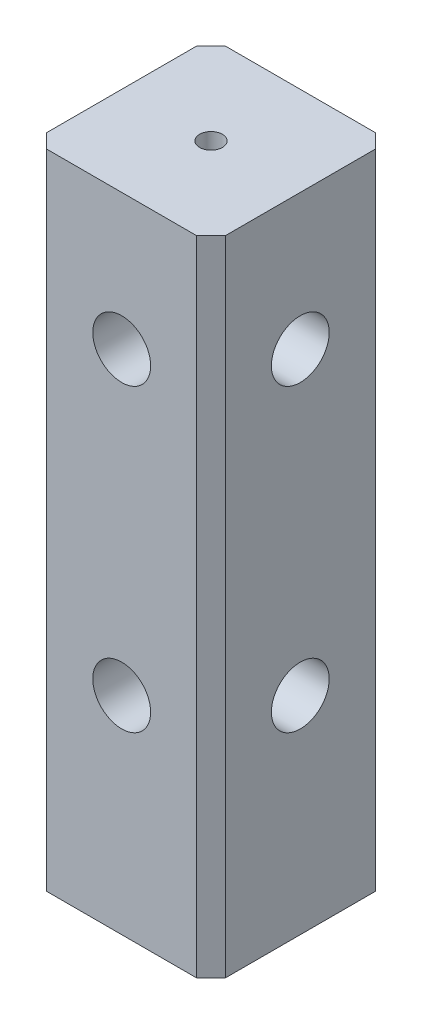
from build123d import *

# Parameters (mm, degrees)
SKETCH1_W           = 25
SKETCH1_H           = 25
BOSS_EXTRUDE1_DEPTH = 90
SKETCH2_R           = 4.05
CUT_EXTRUDE1_DEPTH  = 8
SKETCH3_R           = 4.05
CUT_EXTRUDE7_DEPTH  = 8
CHAMFER1_SIZE       = 2
SKETCH5_R           = 1.6
CUT_EXTRUDE8_DEPTH  = 10


with BuildPart() as part:
    # Sketch1 → Boss-Extrude1 (new body)
    with BuildSketch(Plane(origin=(0, 0, 0), x_dir=(1, 0, 0), z_dir=(0, 1, 0))):
        Rectangle(SKETCH1_W, SKETCH1_H)
    extrude(amount=BOSS_EXTRUDE1_DEPTH)

    # Sketch2 → Cut-Extrude1 (cut)
    with BuildSketch(Plane(origin=(12.5, 0, 0), x_dir=(0, 0, -1), z_dir=(1, 0, 0))):
        with Locations((0, 71)):
            Circle(SKETCH2_R)
        with Locations((0, 29)):
            Circle(SKETCH2_R)
    extrude(amount=-CUT_EXTRUDE1_DEPTH, mode=Mode.SUBTRACT)

    # Sketch3 → Cut-Extrude7 (cut)
    with BuildSketch(Plane.XY.offset(12.5)):
        with Locations((0, 29)):
            Circle(SKETCH3_R)
        with Locations((0, 71)):
            Circle(SKETCH3_R)
    extrude(amount=-CUT_EXTRUDE7_DEPTH, mode=Mode.SUBTRACT)

    # Chamfer1
    chamfer1_edges = [part.edges().sort_by_distance(p)[0] for p in [
        (12.5, 45, 12.5),
        (-12.5, 45, 12.5),
        (-12.5, 45, -12.5),
        (12.5, 45, -12.5),
    ]]
    chamfer(chamfer1_edges, length=CHAMFER1_SIZE)

    # Sketch5 → Cut-Extrude8 (cut)
    with BuildSketch(Plane(origin=(0, 90, 0), x_dir=(1, 0, 0), z_dir=(0, 1, 0))):
        Circle(SKETCH5_R)
    extrude(amount=-CUT_EXTRUDE8_DEPTH, mode=Mode.SUBTRACT)


solid = part.part
